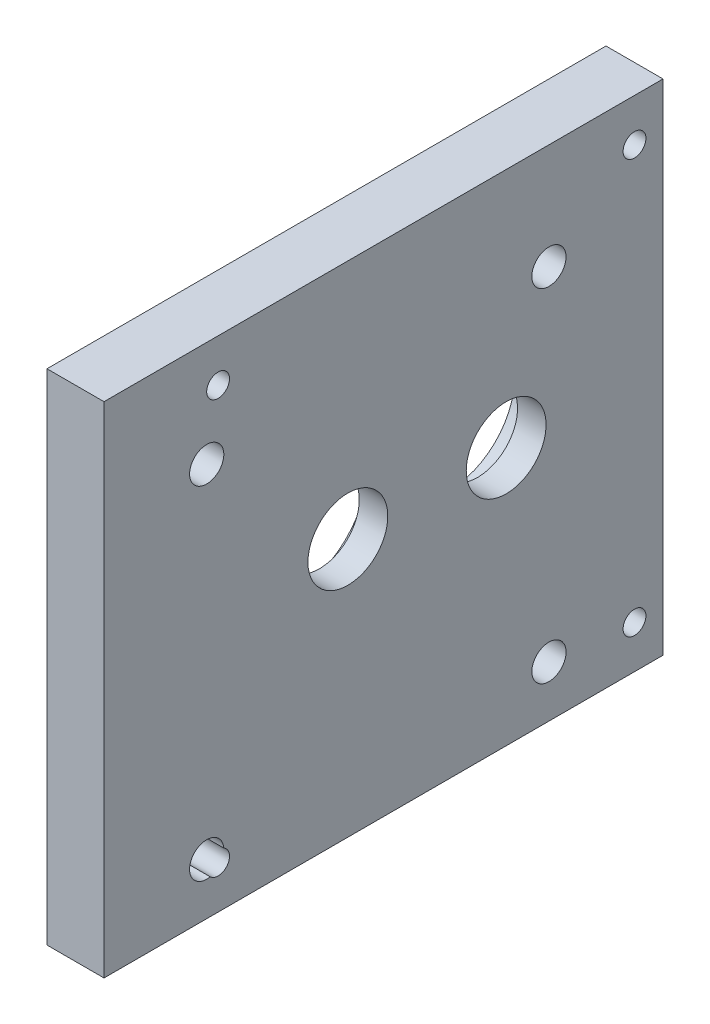
from build123d import *

# Parameters (mm, degrees)
SKETCH1_W           = 20
SKETCH1_H           = 196
BOSS_EXTRUDE1_DEPTH = 175
SKETCH2_R           = 27.5
SKETCH2_R_2         = 23
CUT_EXTRUDE1_DEPTH  = 10
SKETCH3_R           = 14
CUT_EXTRUDE2_DEPTH  = 11
SKETCH4_R           = 4
CUT_EXTRUDE3_DEPTH  = 21
SKETCH5_R           = 6
CUT_EXTRUDE4_DEPTH  = 21


with BuildPart() as part:
    # Sketch1 → Boss-Extrude1 (new body)
    with BuildSketch(Plane(origin=(114, 0, 0), x_dir=(1, 0, 0), z_dir=(0, 1, 0))):
        with Locations((-114, 0)):
            Rectangle(SKETCH1_W, SKETCH1_H)
    extrude(amount=BOSS_EXTRUDE1_DEPTH)

    # Sketch2 → Cut-Extrude1 (cut)
    with BuildSketch(Plane.ZY.offset(10)):
        with Locations((12.5, 90.5)):
            Circle(SKETCH2_R)
        with Locations((-43, 90.5)):
            Circle(SKETCH2_R_2)
    extrude(amount=-CUT_EXTRUDE1_DEPTH, mode=Mode.SUBTRACT)

    # Sketch3 → Cut-Extrude2 (cut, through all)
    with BuildSketch(Plane.ZY):
        with Locations((12.5, 90.5)):
            Circle(SKETCH3_R)
        with Locations((-43, 90.5)):
            Circle(SKETCH3_R)
    extrude(amount=-CUT_EXTRUDE2_DEPTH, mode=Mode.SUBTRACT)

    # Sketch4 → Cut-Extrude3 (cut, through all)
    with BuildSketch(Plane.ZY.offset(10)):
        with Locations((58, 15)):
            Circle(SKETCH4_R)
        with Locations((-88, 15)):
            Circle(SKETCH4_R)
        with Locations((-88, 160)):
            Circle(SKETCH4_R)
        with Locations((58, 160)):
            Circle(SKETCH4_R)
    extrude(amount=-CUT_EXTRUDE3_DEPTH, mode=Mode.SUBTRACT)

    # Sketch5 → Cut-Extrude4 (cut, through all)
    with BuildSketch(Plane.ZY.offset(10)):
        with Locations((62, 138)):
            Circle(SKETCH5_R)
        with Locations((62, 18)):
            Circle(SKETCH5_R)
        with Locations((-58, 138)):
            Circle(SKETCH5_R)
        with Locations((-58, 18)):
            Circle(SKETCH5_R)
    extrude(amount=-CUT_EXTRUDE4_DEPTH, mode=Mode.SUBTRACT)


solid = part.part
